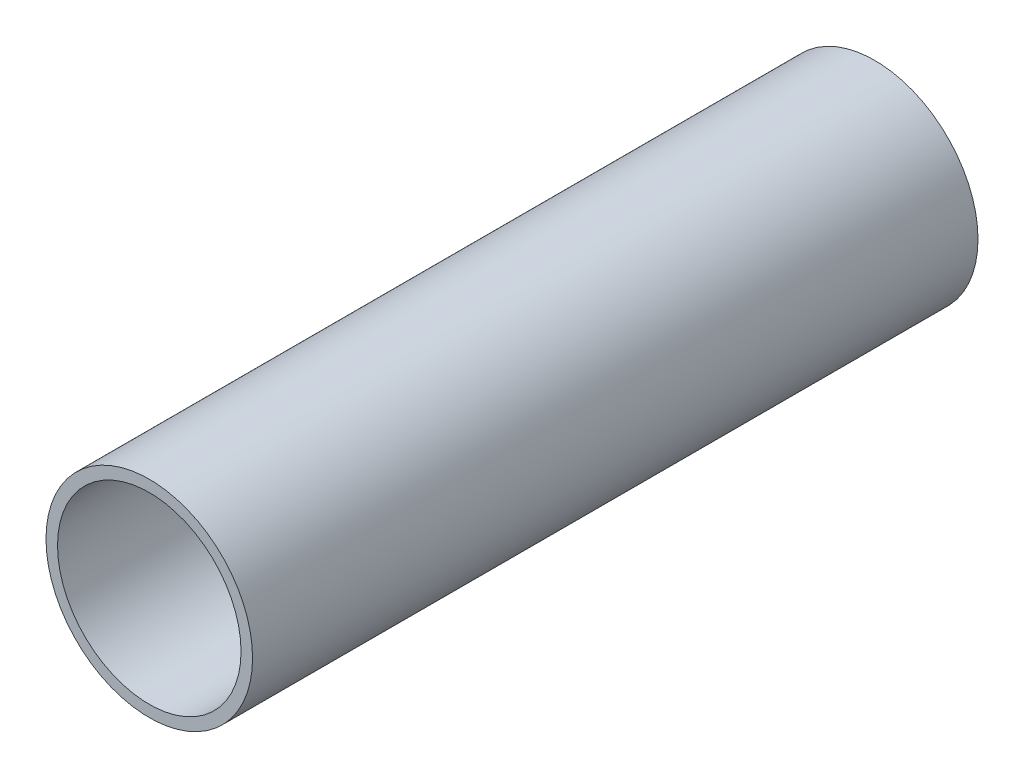
from build123d import *

# Parameters (mm, degrees)
SKETCH1_R           = 56.945
SKETCH1_R_2         = 50.595
BOSS_EXTRUDE1_DEPTH = 400


with BuildPart() as part:
    # Sketch1 → Boss-Extrude1 (new body)
    with BuildSketch(Plane.XY):
        Circle(SKETCH1_R)
        Circle(SKETCH1_R_2, mode=Mode.SUBTRACT)
    extrude(amount=BOSS_EXTRUDE1_DEPTH)


solid = part.part
